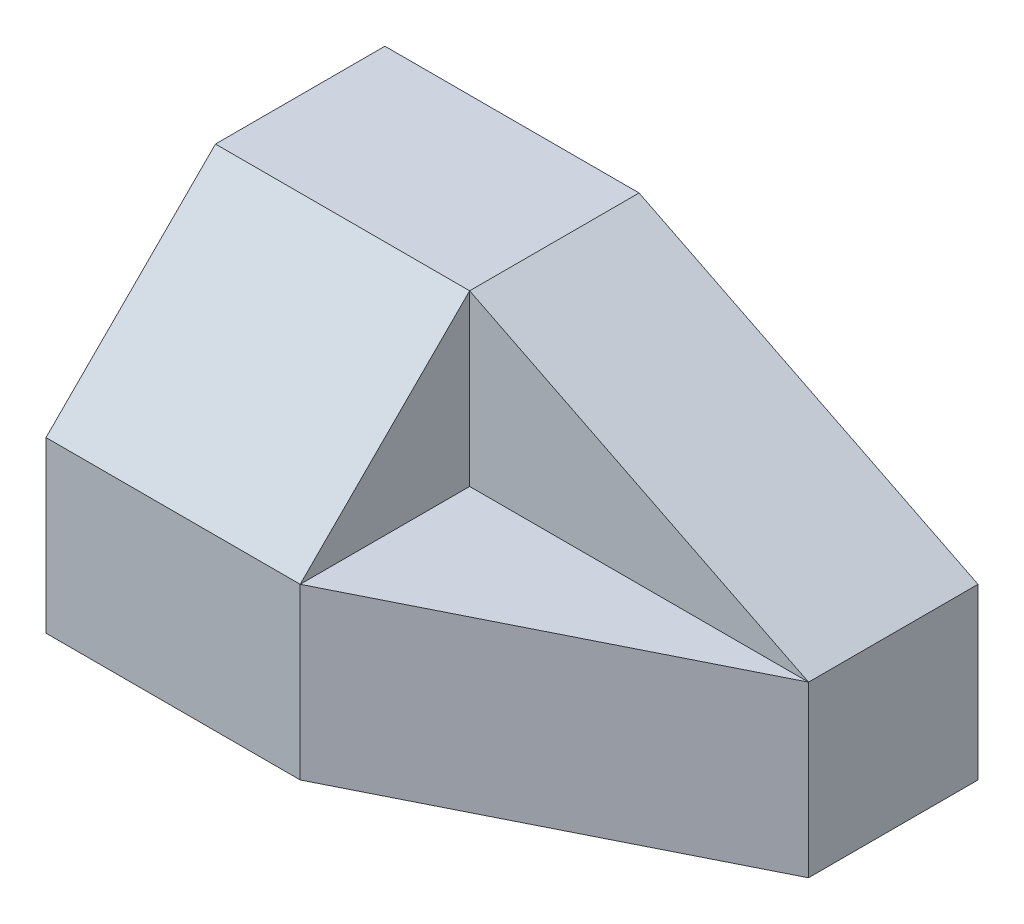
from build123d import *

# Parameters (mm, degrees)
SKETCH_1_W          = 35
SKETCH_1_H          = 20
EXTRUDE_1_DEPTH     = 20
CUT_EXTRUDE_1_DEPTH = 20
CUT_EXTRUDE_2_DEPTH = 32
CUT_EXTRUDE_3_DEPTH = 10
CUT_EXTRUDE_4_DEPTH = 19


with BuildPart() as part:
    # 草圖1 → 填料-伸長1 (new body)
    with BuildSketch(Plane(origin=(0, 0, 0), x_dir=(1, 0, 0), z_dir=(0, 1, 0))):
        Rectangle(SKETCH_1_W, SKETCH_1_H)
    extrude(amount=EXTRUDE_1_DEPTH)

    # 草圖2 → 除料-伸長1 (cut)
    with BuildSketch(Plane.XY.offset(10)):
        Polygon((17.5, 20), (-2.5, 20), (17.5, 10), align=None)
    extrude(amount=-CUT_EXTRUDE_1_DEPTH, mode=Mode.SUBTRACT)

    # 草圖3 → 除料-伸長2 (cut)
    with BuildSketch(Plane(origin=(0, 0, 0), x_dir=(1, 0, 0), z_dir=(0, 1, 0))):
        Polygon((-2.5, -10), (17.5, -10), (17.5, 0), align=None)
    extrude(amount=CUT_EXTRUDE_2_DEPTH, mode=Mode.SUBTRACT)

    # 草圖4 → 除料-伸長3 (cut)
    with BuildSketch(Plane(origin=(0, 20, 0), x_dir=(1, 0, 0), z_dir=(0, 1, 0))):
        Polygon((17.5, 0), (-2.5, 0), (-2.5, -10), align=None)
    extrude(amount=-CUT_EXTRUDE_3_DEPTH, mode=Mode.SUBTRACT)

    # 草圖5 → 除料-伸長4 (cut)
    with BuildSketch(Plane(origin=(-2.5, 0, 0), x_dir=(0, 0, -1), z_dir=(1, 0, 0))):
        Polygon((0, 20), (-10, 20), (-10, 10), align=None)
    extrude(amount=-CUT_EXTRUDE_4_DEPTH, mode=Mode.SUBTRACT)


solid = part.part
